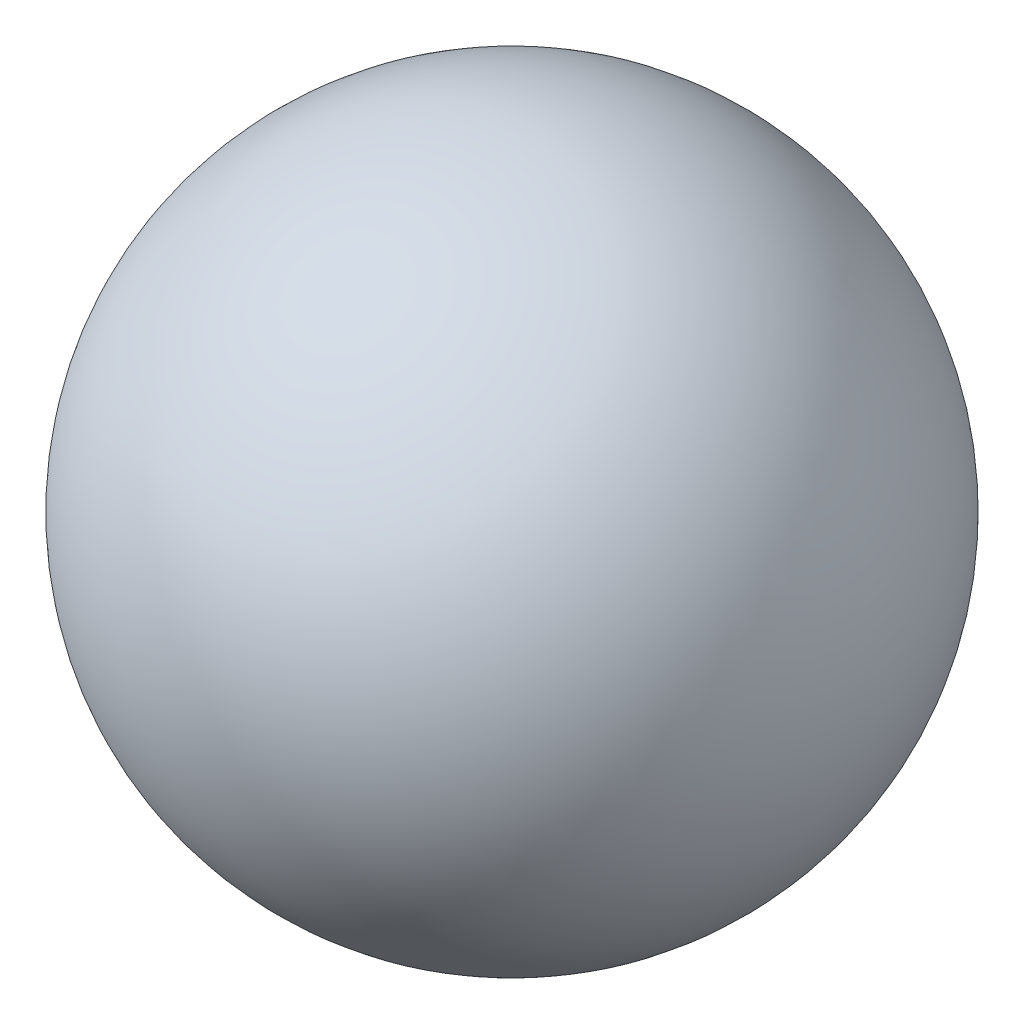
from build123d import *


with BuildPart() as part:
    # Sketch1 → Revolve1 (revolve)
    with BuildSketch(Plane.XY):
        with BuildLine():
            Line((0, 100), (0, -100))
            ThreePointArc((0, -100), (100, 0), (0, 100))
        make_face()
    revolve(axis=Axis((0, -100, 0), (0, 1, 0)))


solid = part.part
